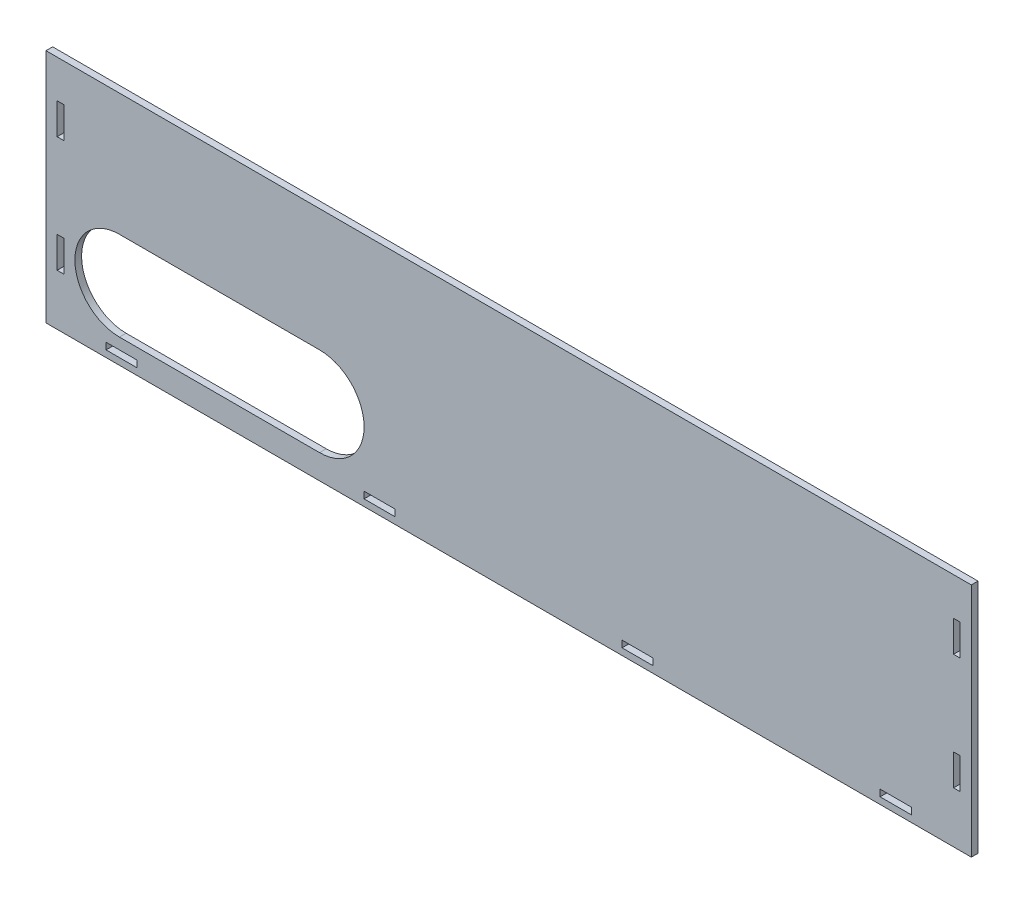
from build123d import *

# Parameters (mm, degrees)
SKETCH1_W           = 416
SKETCH1_H           = 106
BOSS_EXTRUDE1_DEPTH = 3
SKETCH2_W           = 3
SKETCH2_H           = 14
SKETCH2_W_2         = 14
SKETCH2_H_2         = 3
CUT_EXTRUDE1_DEPTH  = 3
CUT_EXTRUDE2_DEPTH  = 3


with BuildPart() as part:
    # Sketch1 → Boss-Extrude1 (new body)
    with BuildSketch(Plane.XY):
        with Locations((0, -3)):
            Rectangle(SKETCH1_W, SKETCH1_H)
    extrude(amount=BOSS_EXTRUDE1_DEPTH)

    # Sketch2 → Cut-Extrude1 (cut)
    with BuildSketch(Plane.XY.offset(3)):
        with Locations((201.5, 26)):
            Rectangle(SKETCH2_W, SKETCH2_H)
        with Locations((-201.5, 26)):
            Rectangle(SKETCH2_W, SKETCH2_H)
        with Locations((201.5, -26)):
            Rectangle(SKETCH2_W, SKETCH2_H)
        with Locations((-201.5, -26)):
            Rectangle(SKETCH2_W, SKETCH2_H)
        with Locations((174, -51.5)):
            Rectangle(SKETCH2_W_2, SKETCH2_H_2)
        with Locations((-174, -51.5)):
            Rectangle(SKETCH2_W_2, SKETCH2_H_2)
        with Locations((58, -51.5)):
            Rectangle(SKETCH2_W_2, SKETCH2_H_2)
        with Locations((-58, -51.5)):
            Rectangle(SKETCH2_W_2, SKETCH2_H_2)
    extrude(amount=-CUT_EXTRUDE1_DEPTH, mode=Mode.SUBTRACT)

    # Sketch4 → Cut-Extrude2 (cut)
    with BuildSketch(Plane.XY.offset(3)):
        with BuildLine():
            Line((-175, -5), (-85, -5))
            ThreePointArc((-85, -5), (-65, -25), (-85, -45))
            Line((-85, -45), (-175, -45))
            ThreePointArc((-175, -45), (-195, -25), (-175, -5))
        make_face()
    extrude(amount=-CUT_EXTRUDE2_DEPTH, mode=Mode.SUBTRACT)


solid = part.part
